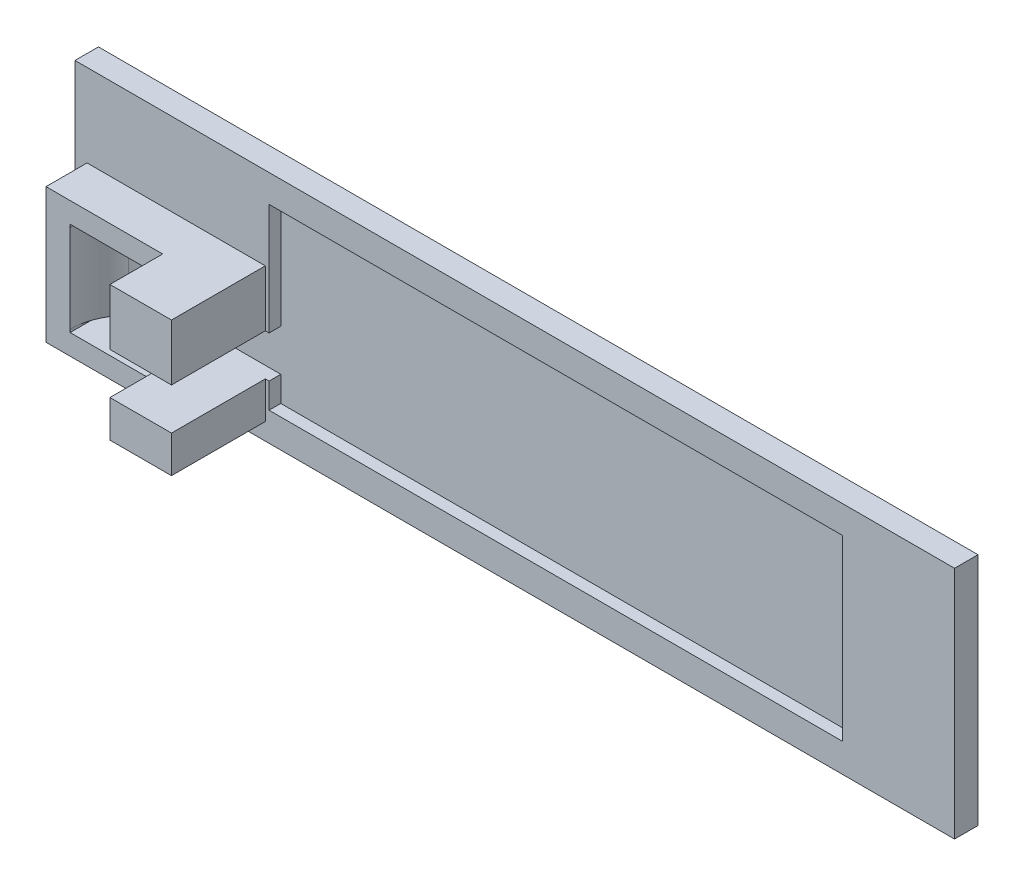
from build123d import *

# Parameters (mm, degrees)
SKETCH1_W                       = 150
SKETCH1_H                       = 40
BOSS_EXTRUDE1_DEPTH             = 2
SKETCH2_W                       = 150
SKETCH2_H                       = 40
BOSS_EXTRUDE2_DEPTH             = 2
CUT_EXTRUDE1_DEPTH              = 12.7
CUT_EXTRUDE1_DEPTH_BACK         = 2.3
BOSS_EXTRUDE3_DEPTH             = 9
BOSS_EXTRUDE4_REACH             = 32.803
BOSS_EXTRUDE4_DIRECTION_2_REACH = 11.197
CUT_EXTRUDE2_DEPTH              = 9
CUT_EXTRUDE3_DEPTH              = 2
SKETCH8_W                       = 10.5
SKETCH8_H                       = 9.597099162
SKETCH8_H_2                     = 6.297094949
BOSS_EXTRUDE5_DEPTH             = 9


with BuildPart() as part:
    # Sketch1 → Boss-Extrude1 (new body)
    with BuildSketch(Plane.XY):
        with Locations((53.542293618, 10.802935989)):
            Rectangle(SKETCH1_W, SKETCH1_H)
        with BuildLine():
            Line((107.411442145, 19.39470724), (107.411442145, 16.563139449))
            ThreePointArc((107.411442145, 16.563139449), (99.879507012, 8.827431039), (90.278173099, 3.889251358))
            ThreePointArc((90.278173099, 3.889251358), (87.976829975, 4.107947017), (85.862026946, 5.041550847))
            Line((85.862026946, 5.041550847), (83.564794922, 4.425052911))
            Line((83.564794922, 4.425052911), (81.157246557, 3.778949869))
            ThreePointArc((81.157246557, 3.778949869), (80.265596131, 1.871389792), (78.431111832, 0.8377103))
            Line((78.431111832, 0.8377103), (63.171073337, -3.257558326))
            ThreePointArc((63.171073337, -3.257558326), (60.782240037, -2.264409978), (59.531114294, 0))
            Line((59.531114294, 0), (51.260116039, 0))
            ThreePointArc((51.260116039, 0), (50.153419477, -2.317171365), (47.784117276, -3.307356952))
            Line((47.784117276, -3.307356952), (15.784117324, -3.309106743))
            ThreePointArc((15.784117324, -3.309106743), (13.343545232, -2.355539788), (12.195889194, 0))
            Line((12.195889194, 0), (0, 0))
            Line((0, 0), (0, 7.1))
            Line((0, 7.1), (11.639427583, 7.1))
            ThreePointArc((11.639427583, 7.1), (13.95708374, 11.772480363), (17.201849985, 15.85599537))
            ThreePointArc((17.201849985, 15.85599537), (17.97614749, 16.386455083), (18.8959739, 16.573119247))
            Line((18.8959739, 16.573119247), (44.695973562, 16.568946787))
            ThreePointArc((44.695973562, 16.568946787), (45.539742509, 16.358143902), (46.249834575, 15.85599537))
            ThreePointArc((46.249834575, 15.85599537), (49.049011998, 12.449181276), (51.19972816, 8.6))
            Line((51.19972816, 8.6), (59.697013712, 8.6))
            ThreePointArc((59.697013712, 8.6), (60.947722352, 11.657213146), (63.162897087, 14.107483583))
            ThreePointArc((63.162897087, 14.107483583), (63.865840812, 15.804539858), (65.562897087, 16.507483583))
            Line((65.562897087, 16.507483583), (72.962892379, 16.499136125))
            ThreePointArc((72.962892379, 16.499136125), (74.529247661, 15.732293003), (75.162897087, 14.107483583))
            ThreePointArc((75.162897087, 14.107483583), (76.943795958, 13.247586891), (78.431584017, 11.944701709))
            Line((78.431584017, 11.944701709), (84.544097467, 13.585089744))
            ThreePointArc((84.544097467, 13.585089744), (85.264438336, 15.182566708), (86.505516367, 16.419720272))
            ThreePointArc((86.505516367, 16.419720272), (94.138787289, 25.104262189), (104.023703334, 19.106218503))
            Line((104.023703334, 19.106218503), (107.411442145, 19.39470724))
        make_face(mode=Mode.SUBTRACT)
    extrude(amount=BOSS_EXTRUDE1_DEPTH)

    # Sketch2 → Boss-Extrude2 (add)
    with BuildSketch(Plane.XY):
        with Locations((53.542293618, 10.802935989)):
            Rectangle(SKETCH2_W, SKETCH2_H)
    extrude(amount=-BOSS_EXTRUDE2_DEPTH)

    # Sketch3 → Cut-Extrude1 (cut, two sides)
    with BuildSketch(Plane(origin=(0, 0, 0), x_dir=(1, 0, 0), z_dir=(0, 1, 0))) as cut_extrude1_sk:
        with BuildLine():
            Line((0, -0.8), (0, -17.6))
            ThreePointArc((0, -17.6), (-15.540418318, -9.2), (0, -0.8))
        make_face()
    extrude(amount=CUT_EXTRUDE1_DEPTH, mode=Mode.SUBTRACT)
    extrude(cut_extrude1_sk.sketch, amount=-CUT_EXTRUDE1_DEPTH_BACK, mode=Mode.SUBTRACT)

    # Sketch4 → Boss-Extrude3 (add)
    with BuildSketch(Plane.XY):
        Polygon((0, 7.1), (0, 12.7), (-12.497856815, 12.7), (-15.345436436, 12.7), (-15.345436436, 16.697099162), (-12.345546973, 16.697099162), (4, 16.697099162), (11, 16.697099162), (11, 7.1), align=None)
        Polygon((0, 0), (0, -2.3), (-12.497856815, -2.3), (-15.345436436, -2.3), (-15.345436436, -6.297094949), (-12.345436436, -6.297094949), (4, -6.297094949), (11, -6.297094949), (11, 0), align=None)
    extrude(amount=BOSS_EXTRUDE3_DEPTH)

    # Boss-Extrude4: up to this face of the body (flat: up to its plane)
    boss_extrude4_end = Plane(part.part.faces().sort_by_distance((-2.172718218, 16.697099162, 5.5))[0])
    # Sketch5 → Boss-Extrude4 (add, up to the picked face)
    with BuildSketch(Plane(origin=(0, 0, 0), x_dir=(1, 0, 0), z_dir=(0, 1, 0)), mode=Mode.PRIVATE) as boss_extrude4_sk1:
        with BuildLine():
            Line((-15.290812019, -9), (-19.400060853, -9))
            Line((-19.400060853, -9), (-19.400060853, -2))
            Line((-19.400060853, -2), (-12.345436436, -2))
            ThreePointArc((-12.345436436, -2), (-14.524477307, -5.20278927), (-15.290812019, -9))
        make_face()
    boss_extrude4_tool1 = split(extrude(boss_extrude4_sk1.sketch, amount=BOSS_EXTRUDE4_REACH, mode=Mode.PRIVATE), bisect_by=boss_extrude4_end, keep=Keep.BOTH, mode=Mode.PRIVATE)
    add(boss_extrude4_tool1.solids().sort_by_distance((-16.816054, 0, 5.171228))[0])

    # Boss-Extrude4 direction 2: up to this face of the body (flat: up to its plane)
    boss_extrude4_direction_2_end = Plane(part.part.faces().sort_by_distance((-2.172718218, -6.297094949, 5.5))[0])
    # Sketch5 → Boss-Extrude4 direction 2 (add, up to the picked face)
    with BuildSketch(Plane(origin=(0, 0, 0), x_dir=(1, 0, 0), z_dir=(0, 1, 0)), mode=Mode.PRIVATE) as boss_extrude4_direction_2_sk1:
        with BuildLine():
            Line((-15.290812019, -9), (-19.400060853, -9))
            Line((-19.400060853, -9), (-19.400060853, -2))
            Line((-19.400060853, -2), (-12.345436436, -2))
            ThreePointArc((-12.345436436, -2), (-14.524477307, -5.20278927), (-15.290812019, -9))
        make_face()
    boss_extrude4_direction_2_tool1 = split(extrude(boss_extrude4_direction_2_sk1.sketch, amount=-BOSS_EXTRUDE4_DIRECTION_2_REACH, mode=Mode.PRIVATE), bisect_by=boss_extrude4_direction_2_end, keep=Keep.BOTH, mode=Mode.PRIVATE)
    add(boss_extrude4_direction_2_tool1.solids().sort_by_distance((-16.816054, 0, 5.171228))[0])

    # Sketch6 → Cut-Extrude2 (cut)
    with BuildSketch(Plane.XY.offset(9)):
        Polygon((0, 7.1), (0, 12.7), (-15.290812019, 12.7), (-15.290812019, 13.2), (0.5, 13.2), (0.5, 7.1), align=None)
        Polygon((-15.290812019, -2.3), (0, -2.3), (0, 0), (0.5, 0), (0.5, -2.8), (-15.290812019, -2.8), align=None)
    extrude(amount=-CUT_EXTRUDE2_DEPTH, mode=Mode.SUBTRACT)

    # Sketch7 → Cut-Extrude3 (cut)
    with BuildSketch(Plane.XY.offset(2)):
        Polygon((11.639427583, 7.1), (11.639427583, 26.1), (109.411442143, 26.1), (109.411442143, -4.30823185), (11.639427583, -4.30823185), align=None)
    extrude(amount=-CUT_EXTRUDE3_DEPTH, mode=Mode.SUBTRACT)

    # Sketch8 → Boss-Extrude5 (add)
    with BuildSketch(Plane.XY.offset(9)):
        with Locations((5.75, 11.898549581)):
            Rectangle(SKETCH8_W, SKETCH8_H)
        with Locations((5.75, -3.148547475)):
            Rectangle(SKETCH8_W, SKETCH8_H_2)
    extrude(amount=BOSS_EXTRUDE5_DEPTH)


solid = part.part
